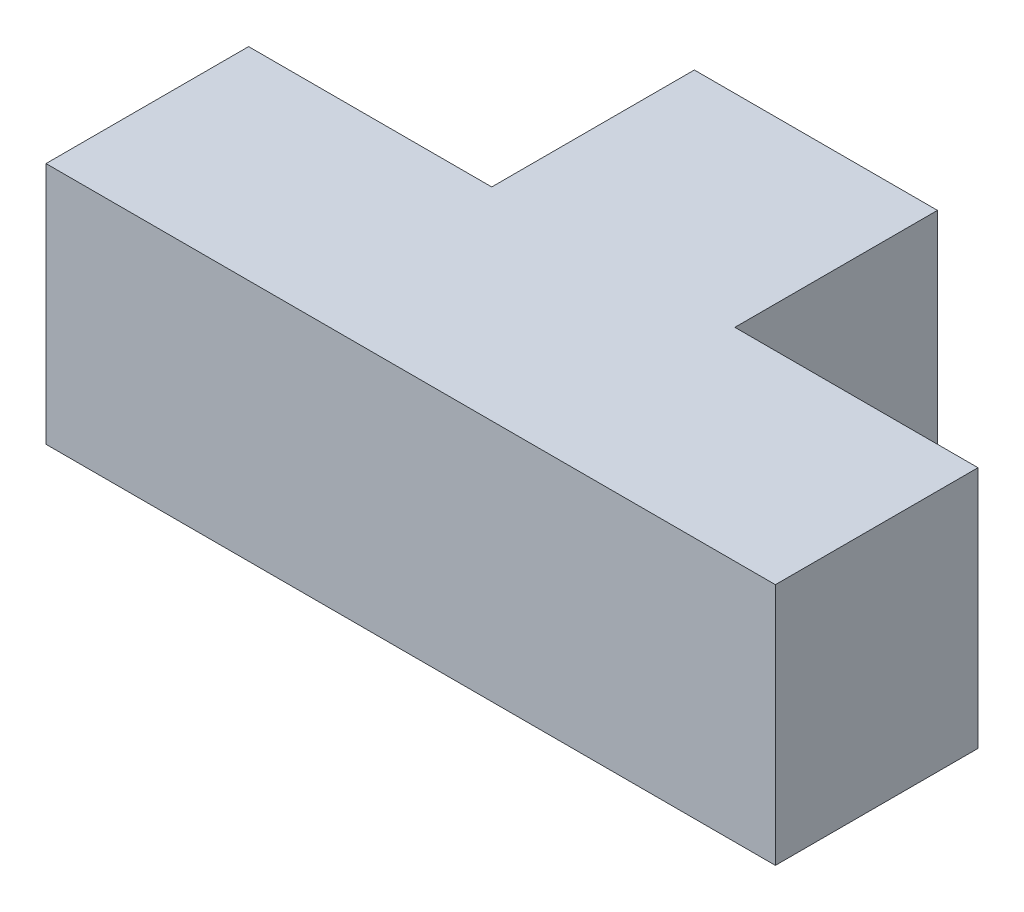
from build123d import *

# Parameters (mm, degrees)
BOSS_EXTRUDE1_DEPTH = 30


with BuildPart() as part:
    # Sketch1 → Boss-Extrude1 (new body)
    with BuildSketch(Plane(origin=(0, 0, 0), x_dir=(1, 0, 0), z_dir=(0, 1, 0))):
        Polygon((0, 0), (0, 25), (30, 25), (30, 50), (60, 50), (60, 25), (90, 25), (90, 0), align=None)
    extrude(amount=BOSS_EXTRUDE1_DEPTH)


solid = part.part
